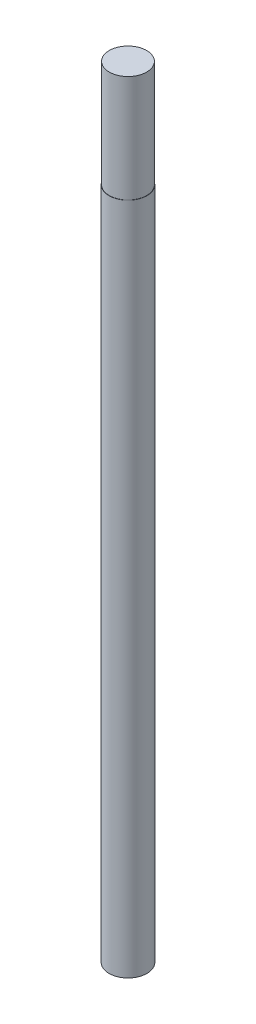
from build123d import *

# Parameters (mm, degrees)
SKETCH1_R      = 3.55
EXTRUDE1_DEPTH = 126
SKETCH2_R      = 3.5
EXTRUDE2_DEPTH = 20


with BuildPart() as part:
    # Sketch1 → Extrude1 (new body)
    with BuildSketch(Plane(origin=(0, 0, 0), x_dir=(1, 0, 0), z_dir=(0, 1, 0))):
        Circle(SKETCH1_R)
    extrude(amount=EXTRUDE1_DEPTH)

    # Sketch2 → Extrude2 (add)
    with BuildSketch(Plane(origin=(0, 126, 0), x_dir=(1, 0, 0), z_dir=(0, 1, 0))):
        Circle(SKETCH2_R)
    extrude(amount=EXTRUDE2_DEPTH)


solid = part.part
